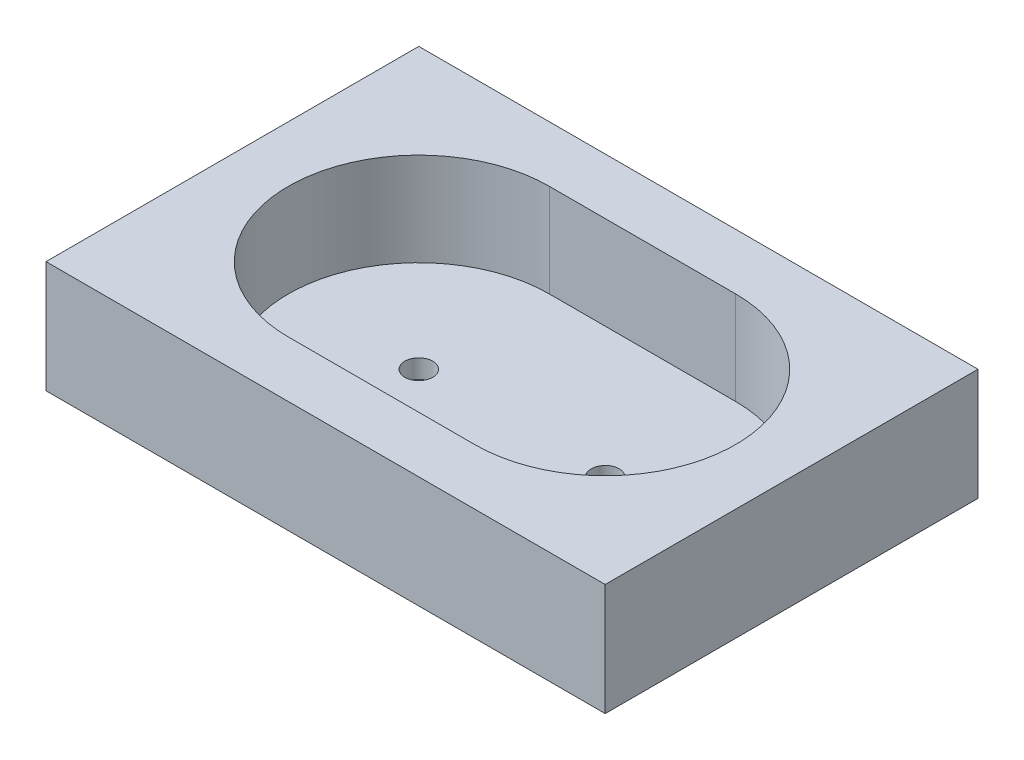
from build123d import *

# Parameters (mm, degrees)
SKETCH1_W           = 60
SKETCH1_H           = 40
BOSS_EXTRUDE1_DEPTH = 10
SKETCH1_3_W         = 60
SKETCH1_3_H         = 40
SKETCH1_3_R         = 1.5
BOSS_EXTRUDE2_DEPTH = 2


with BuildPart() as part:
    # Sketch1 → Boss-Extrude1 (new body)
    with BuildSketch(Plane(origin=(0, 0, 0), x_dir=(1, 0, 0), z_dir=(0, 1, 0))):
        with Locations((-10, 0)):
            Rectangle(SKETCH1_W, SKETCH1_H)
        with BuildLine():
            ThreePointArc((-20, -14), (-34, 0), (-20, 14))
            Line((-20, 14), (0, 14))
            ThreePointArc((0, 14), (14, 0), (0, -14))
            Line((0, -14), (-20, -14))
        make_face(mode=Mode.SUBTRACT)
    extrude(amount=BOSS_EXTRUDE1_DEPTH)

    # Sketch1_3 → Boss-Extrude2 (add)
    with BuildSketch(Plane(origin=(0, 0, 0), x_dir=(1, 0, 0), z_dir=(0, 1, 0))):
        with Locations((-10, 0)):
            Rectangle(SKETCH1_3_W, SKETCH1_3_H)
        with Locations((-20, 0)):
            Circle(SKETCH1_3_R, mode=Mode.SUBTRACT)
        Circle(SKETCH1_3_R, mode=Mode.SUBTRACT)
    extrude(amount=-BOSS_EXTRUDE2_DEPTH)


solid = part.part
